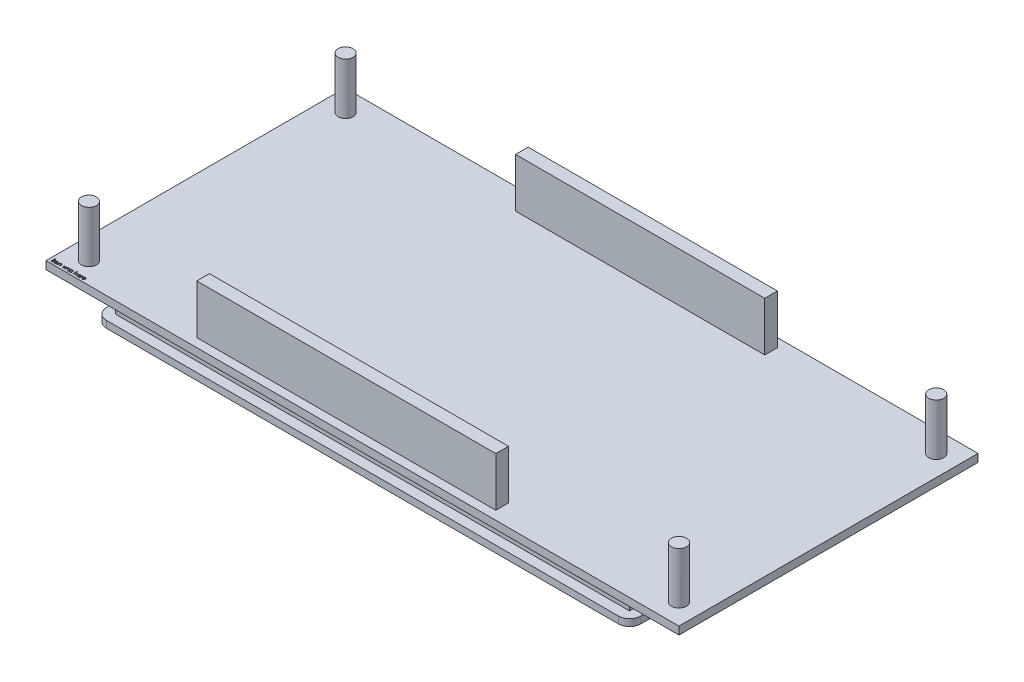
from build123d import *

# Parameters (mm, degrees)
SKETCH1_W           = 127
SKETCH1_H           = 60
BOSS_EXTRUDE1_DEPTH = 1.57
SKETCH2_R           = 1.5
BOSS_EXTRUDE2_DEPTH = 10.33
SKETCH3_W           = 107.2
SKETCH3_H           = 60
SKETCH3_W_2         = 88.657891226
SKETCH3_H_2         = 49.621954044
BOSS_EXTRUDE3_DEPTH = 4.13
SKETCH4_W           = 107.2
SKETCH4_H           = 60
SKETCH4_W_2         = 103.2
SKETCH4_H_2         = 56
CUT_EXTRUDE1_DEPTH  = 2.75
FILLET1_R           = 2.25
SKETCH5_W           = 88.657891226
SKETCH5_H           = 49.621954044
BOSS_EXTRUDE4_DEPTH = 4
SKETCH6_W           = 50
SKETCH6_H           = 2.54
SKETCH6_W_2         = 60
BOSS_EXTRUDE5_DEPTH = 9.85
BOSS_EXTRUDE6_DEPTH = 0.1


with BuildPart() as part:
    # Sketch1 → Boss-Extrude1 (new body)
    with BuildSketch(Plane(origin=(0, 0, 0), x_dir=(1, 0, 0), z_dir=(0, 1, 0))):
        with Locations((63.5, 30)):
            Rectangle(SKETCH1_W, SKETCH1_H)
    extrude(amount=BOSS_EXTRUDE1_DEPTH)

    # Sketch2 → Boss-Extrude2 (add)
    with BuildSketch(Plane(origin=(0, 1.57, 0), x_dir=(1, 0, 0), z_dir=(0, 1, 0))):
        with Locations((4.31, 55.81)):
            Circle(SKETCH2_R)
        with Locations((4.31, 4.31)):
            Circle(SKETCH2_R)
        with Locations((122.81, 4.19)):
            Circle(SKETCH2_R)
        with Locations((122.81, 55.81)):
            Circle(SKETCH2_R)
    extrude(amount=BOSS_EXTRUDE2_DEPTH)

    # Sketch3 → Boss-Extrude3 (add)
    with BuildSketch(Plane.XZ):
        with Locations((63.5, -30)):
            Rectangle(SKETCH3_W, SKETCH3_H)
        with Locations((63.5, -30)):
            Rectangle(SKETCH3_W_2, SKETCH3_H_2, mode=Mode.SUBTRACT)
    extrude(amount=BOSS_EXTRUDE3_DEPTH)

    # Sketch4 → Cut-Extrude1 (cut)
    with BuildSketch(Plane.XZ):
        with Locations((63.5, -30)):
            Rectangle(SKETCH4_W, SKETCH4_H)
        with Locations((63.5, -30)):
            Rectangle(SKETCH4_W_2, SKETCH4_H_2, mode=Mode.SUBTRACT)
    extrude(amount=CUT_EXTRUDE1_DEPTH, mode=Mode.SUBTRACT)

    # Fillet1
    fillet1_edges = [part.edges().sort_by_distance(p)[0] for p in [
        (117.1, -3.44, -60),
        (117.1, -3.44, 0),
        (9.9, -3.44, 0),
        (9.9, -3.44, -60),
    ]]
    fillet(fillet1_edges, radius=FILLET1_R)

    # Sketch5 → Boss-Extrude4 (add)
    with BuildSketch(Plane.XZ):
        with Locations((63.5, -30)):
            Rectangle(SKETCH5_W, SKETCH5_H)
    extrude(amount=BOSS_EXTRUDE4_DEPTH)

    # Sketch6 → Boss-Extrude5 (add)
    with BuildSketch(Plane(origin=(0, 1.57, 0), x_dir=(1, 0, 0), z_dir=(0, 1, 0))):
        with Locations((63.5, 56.98)):
            Rectangle(SKETCH6_W, SKETCH6_H)
        with Locations((58.5, 3.02)):
            Rectangle(SKETCH6_W_2, SKETCH6_H)
    extrude(amount=BOSS_EXTRUDE5_DEPTH)

    # Sketch7 → Boss-Extrude6 (add)
    with BuildSketch(Plane(origin=(0, 1.57, 0), x_dir=(1, 0, 0), z_dir=(0, 1, 0))):
        with BuildLine():
            Line((0.608390087, 1.15544413), (0.754724222, 1.15544413))
            add(Edge.make_bspline(
                [(0.754724222, 1.15544413), (0.761887467, 1.155406469), (0.77577162, 1.155333473), (0.7959615, 1.154201373), (0.814871959, 1.15265773), (0.832508482, 1.150208424), (0.848862918, 1.147253043), (0.863984555, 1.143674083), (0.877825306, 1.139382665), (0.894349464, 1.132558462), (0.913189605, 1.122417783), (0.933589261, 1.107433091), (0.951033027, 1.089104706), (0.966072952, 1.068429851), (0.978030334, 1.045686472), (0.986680898, 1.021416645), (0.992157586, 0.995933415), (0.992720822, 0.978438448), (0.993005472, 0.969596774)],
                knots=[0, 0, 0, 0, 2.1486e-05, 4.1646e-05, 6.0648e-05, 7.839e-05, 9.504e-05, 0.00011049, 0.000124983, 0.000138459, 0.000164071, 0.000188981, 0.000214056, 0.00023966, 0.000265467, 0.000290843, 0.000316773, 0.000343267, 0.000343267, 0.000343267, 0.000343267], degree=3))
            add(Edge.make_bspline(
                [(0.993005472, 0.969596774), (0.992771211, 0.961314083), (0.992310866, 0.945037815), (0.987908846, 0.921231935), (0.981017274, 0.898570959), (0.971437578, 0.877137591), (0.95898715, 0.857416102), (0.944231796, 0.839247403), (0.926429624, 0.823400748), (0.913091787, 0.814541554), (0.90631677, 0.810041485)],
                knots=[0, 0, 0, 0, 2.4827e-05, 4.8786e-05, 7.2358e-05, 9.5759e-05, 0.000118979, 0.000142139, 0.000165758, 0.000190141, 0.000190141, 0.000190141, 0.000190141], degree=3))
            add(Edge.make_bspline(
                [(0.90631677, 0.810041485), (0.914836862, 0.806770414), (0.931137908, 0.800512045), (0.953570624, 0.789447302), (0.972898091, 0.777412564), (0.989268908, 0.764270025), (1.003269834, 0.750103851), (1.015495465, 0.734706327), (1.025927188, 0.717876593), (1.034865671, 0.699790121), (1.041840405, 0.680631592), (1.047063813, 0.660580712), (1.050056838, 0.639709378), (1.050482761, 0.625505369), (1.05069778, 0.618334755)],
                knots=[0, 0, 0, 0, 2.7369e-05, 5.2364e-05, 7.4914e-05, 9.5539e-05, 0.000115193, 0.00013455, 0.000154393, 0.000174484, 0.00019497, 0.000215449, 0.000236547, 0.000258057, 0.000258057, 0.000258057, 0.000258057], degree=3))
            add(Edge.make_bspline(
                [(1.05069778, 0.618334755), (1.050488456, 0.611013282), (1.050076604, 0.596608079), (1.047038039, 0.575446265), (1.04189323, 0.555223062), (1.034806556, 0.535807666), (1.025557489, 0.517237637), (1.014301496, 0.499491938), (1.000880447, 0.482748867), (0.985866975, 0.466822376), (0.96888223, 0.452502136), (0.950557425, 0.43974877), (0.930661785, 0.429260328), (0.909522072, 0.420449752), (0.886901147, 0.413719638), (0.862900588, 0.40901123), (0.837541095, 0.405838722), (0.820139006, 0.405577892), (0.811214607, 0.40544413)],
                knots=[0, 0, 0, 0, 2.196e-05, 4.3207e-05, 6.3978e-05, 8.4464e-05, 0.000105091, 0.000126097, 0.000147379, 0.000169376, 0.000191653, 0.000213907, 0.000236222, 0.000258989, 0.000282518, 0.000306885, 0.000332303, 0.000359061, 0.000359061, 0.000359061, 0.000359061], degree=3))
            Line((0.811214607, 0.40544413), (0.608390087, 0.40544413))
            Line((0.608390087, 0.40544413), (0.608390087, 1.15544413))
        make_face()
        with BuildLine():
            Line((0.67569778, 1.078521053), (0.67569778, 0.838136437))
            Line((0.67569778, 0.838136437), (0.720920135, 0.838136437))
            add(Edge.make_bspline(
                [(0.720920135, 0.838136437), (0.727530592, 0.838222135), (0.74030334, 0.838387721), (0.758800461, 0.838862046), (0.775970107, 0.840190198), (0.791782643, 0.841517968), (0.806213167, 0.843676809), (0.819229709, 0.846246549), (0.831036551, 0.848964315), (0.844652168, 0.853586347), (0.860096371, 0.860417278), (0.876560608, 0.871018386), (0.891075137, 0.883645033), (0.903331677, 0.898214524), (0.913362706, 0.914257279), (0.920329931, 0.931517324), (0.925054349, 0.949564496), (0.925481106, 0.961954121), (0.92569778, 0.96824461)],
                knots=[0, 0, 0, 0, 1.9834e-05, 3.8323e-05, 5.5493e-05, 7.1489e-05, 8.5916e-05, 9.9234e-05, 0.000111296, 0.000122223, 0.000142329, 0.000161791, 0.000180744, 0.000199827, 0.000218715, 0.000237241, 0.000255497, 0.000274325, 0.000274325, 0.000274325, 0.000274325], degree=3))
            add(Edge.make_bspline(
                [(0.92569778, 0.96824461), (0.925585027, 0.972407276), (0.92536385, 0.980572798), (0.923552428, 0.992476231), (0.920473662, 1.003671321), (0.91651917, 1.014311488), (0.910993023, 1.024064027), (0.904486566, 1.03326614), (0.896625347, 1.041604451), (0.887677351, 1.049397915), (0.877389789, 1.056307457), (0.865768798, 1.062359049), (0.852657153, 1.067232073), (0.838275827, 1.07149982), (0.822403451, 1.074497311), (0.80522319, 1.076994466), (0.786594321, 1.078265768), (0.773706085, 1.07843406), (0.767043934, 1.078521053)],
                knots=[0, 0, 0, 0, 1.2484e-05, 2.449e-05, 3.6006e-05, 4.7278e-05, 5.8442e-05, 6.9532e-05, 8.1013e-05, 9.273e-05, 0.000105065, 0.000118101, 0.00013194, 0.000146964, 0.000163052, 0.000180347, 0.000199026, 0.000219013, 0.000219013, 0.000219013, 0.000219013], degree=3))
            Line((0.767043934, 1.078521053), (0.67569778, 1.078521053))
        make_face(mode=Mode.SUBTRACT)
        with BuildLine():
            Line((0.67569778, 0.76121336), (0.67569778, 0.482367206))
            Line((0.67569778, 0.482367206), (0.771551145, 0.482367206))
            add(Edge.make_bspline(
                [(0.771551145, 0.482367206), (0.778412343, 0.482449438), (0.791636399, 0.482607929), (0.81072952, 0.483125333), (0.828425899, 0.484302249), (0.844644785, 0.486154931), (0.859561311, 0.488164599), (0.872996533, 0.490867016), (0.88505936, 0.493963222), (0.899046712, 0.498749116), (0.914797463, 0.506184074), (0.931771218, 0.517394266), (0.946862551, 0.53074926), (0.959677964, 0.546205885), (0.970180747, 0.563012598), (0.977821201, 0.580829458), (0.982533528, 0.599362071), (0.983103993, 0.611997796), (0.983390087, 0.618334755)],
                knots=[0, 0, 0, 0, 2.0585e-05, 3.9675e-05, 5.7294e-05, 7.3769e-05, 8.8642e-05, 0.000102432, 0.000114858, 0.000125976, 0.000146743, 0.000166911, 0.000186812, 0.000206971, 0.000226942, 0.000246058, 0.000264933, 0.000283923, 0.000283923, 0.000283923, 0.000283923], degree=3))
            add(Edge.make_bspline(
                [(0.983390087, 0.618334755), (0.983330922, 0.622297613), (0.983213546, 0.630159409), (0.981443414, 0.641712799), (0.978869014, 0.652904058), (0.975540849, 0.663763574), (0.970693821, 0.674095011), (0.965035275, 0.684102703), (0.958400689, 0.693799877), (0.948062654, 0.706059645), (0.9330258, 0.72018472), (0.911660062, 0.734014184), (0.887365998, 0.745167286), (0.869745821, 0.749902888), (0.860643693, 0.752349178)],
                knots=[0, 0, 0, 0, 1.1878e-05, 2.3564e-05, 3.4971e-05, 4.6327e-05, 5.7555e-05, 6.9127e-05, 8.0796e-05, 9.2741e-05, 0.00011719, 0.000142359, 0.000168781, 0.000197015, 0.000197015, 0.000197015, 0.000197015], degree=3))
            add(Edge.make_bspline(
                [(0.860643693, 0.752349178), (0.856994601, 0.753089553), (0.849082617, 0.754694839), (0.836180993, 0.756389347), (0.821451878, 0.757899002), (0.804861261, 0.759015679), (0.786388153, 0.760169938), (0.765993099, 0.760618829), (0.743759388, 0.761154384), (0.728332451, 0.761193199), (0.720319174, 0.76121336)],
                knots=[0, 0, 0, 0, 1.1167e-05, 2.4213e-05, 3.9013e-05, 5.5583e-05, 7.4093e-05, 9.4534e-05, 0.000116775, 0.000140813, 0.000140813, 0.000140813, 0.000140813], degree=3))
            Line((0.720319174, 0.76121336), (0.67569778, 0.76121336))
        make_face(mode=Mode.SUBTRACT)
        with BuildLine():
            Line((1.635132876, 0.578521053), (1.694928549, 0.547120812))
            add(Edge.make_bspline(
                [(1.694928549, 0.547120812), (1.690163564, 0.53866867), (1.680892791, 0.522224148), (1.664949774, 0.499631606), (1.648237187, 0.479307096), (1.630000622, 0.461793598), (1.610785691, 0.446525444), (1.590485836, 0.433167339), (1.568995375, 0.421784799), (1.546313291, 0.412194972), (1.522249102, 0.404821509), (1.496744491, 0.399613461), (1.469750599, 0.396394189), (1.451247846, 0.396020231), (1.441773501, 0.395828745)],
                knots=[0, 0, 0, 0, 2.9091e-05, 5.66e-05, 8.2838e-05, 0.000107914, 0.000132292, 0.000156378, 0.000180708, 0.000205151, 0.000230148, 0.000256077, 0.000283155, 0.00031157, 0.00031157, 0.00031157, 0.00031157], degree=3))
            add(Edge.make_bspline(
                [(1.441773501, 0.395828745), (1.431243077, 0.396074568), (1.410701271, 0.396554098), (1.380799897, 0.400688198), (1.352647164, 0.407432275), (1.326244656, 0.416853462), (1.301657031, 0.429159317), (1.278835419, 0.444150635), (1.257659806, 0.461750404), (1.238797476, 0.48211107), (1.221816644, 0.503900061), (1.206832539, 0.526604893), (1.194305947, 0.550168441), (1.184116102, 0.574440697), (1.175886488, 0.599268674), (1.170150766, 0.624878274), (1.166844391, 0.651200185), (1.166337724, 0.669006757), (1.166082395, 0.677980187)],
                knots=[0, 0, 0, 0, 3.1579e-05, 6.1602e-05, 9.0353e-05, 0.000118297, 0.000145509, 0.000172636, 0.000200048, 0.000227895, 0.000255725, 0.000282852, 0.000309401, 0.000335658, 0.000361742, 0.000387766, 0.000414265, 0.000441185, 0.000441185, 0.000441185, 0.000441185], degree=3))
            add(Edge.make_bspline(
                [(1.166082395, 0.677980187), (1.166309354, 0.686400508), (1.166759156, 0.703088472), (1.169594325, 0.727788231), (1.174618959, 0.751794328), (1.181513886, 0.77512671), (1.190417724, 0.79774631), (1.201310343, 0.819666895), (1.214208709, 0.84086514), (1.22416714, 0.85423724), (1.229183357, 0.860972976)],
                knots=[0, 0, 0, 0, 2.5262e-05, 5.0067e-05, 7.4464e-05, 9.8755e-05, 0.000122972, 0.000147294, 0.000172108, 0.000197293, 0.000197293, 0.000197293, 0.000197293], degree=3))
            add(Edge.make_bspline(
                [(1.229183357, 0.860972976), (1.23597786, 0.869087734), (1.249351634, 0.885060194), (1.271970853, 0.906046978), (1.296463753, 0.923627787), (1.322523387, 0.938200745), (1.350452631, 0.94927367), (1.379876051, 0.957525294), (1.411128676, 0.962149154), (1.432494081, 0.962802261), (1.443426145, 0.963136437)],
                knots=[0, 0, 0, 0, 3.173e-05, 6.2454e-05, 9.2267e-05, 0.000121992, 0.000151788, 0.000182188, 0.000213486, 0.00024628, 0.00024628, 0.00024628, 0.00024628], degree=3))
            add(Edge.make_bspline(
                [(1.443426145, 0.963136437), (1.454664918, 0.962846284), (1.476712827, 0.962277069), (1.508862568, 0.956999998), (1.539282721, 0.948631593), (1.567961115, 0.936812924), (1.594900657, 0.921564448), (1.619926239, 0.902676911), (1.643465848, 0.880730178), (1.657160544, 0.863852347), (1.66412927, 0.855263841)],
                knots=[0, 0, 0, 0, 3.3694e-05, 6.6101e-05, 9.7449e-05, 0.000128168, 0.000158916, 0.000190046, 0.000222037, 0.000255183, 0.000255183, 0.000255183, 0.000255183], degree=3))
            add(Edge.make_bspline(
                [(1.66412927, 0.855263841), (1.668870757, 0.848791645), (1.67832217, 0.835890334), (1.690160834, 0.814853657), (1.700437419, 0.792844244), (1.708651625, 0.769506324), (1.715302946, 0.745116413), (1.720115122, 0.719500154), (1.722937183, 0.692665173), (1.723491904, 0.674380911), (1.723774703, 0.665059514)],
                knots=[0, 0, 0, 0, 2.405e-05, 4.794e-05, 7.2274e-05, 9.6842e-05, 0.000122063, 0.000148053, 0.000174947, 0.000202918, 0.000202918, 0.000202918, 0.000202918], degree=3))
            Line((1.723774703, 0.665059514), (1.233390087, 0.665059514))
            add(Edge.make_bspline(
                [(1.233390087, 0.665059514), (1.233720003, 0.657837986), (1.234368769, 0.643637142), (1.237393442, 0.622857689), (1.242161037, 0.603063401), (1.24886155, 0.584402749), (1.256975874, 0.566632008), (1.266915671, 0.549883), (1.278774146, 0.534232015), (1.292001082, 0.519539057), (1.306724031, 0.506454608), (1.322213191, 0.494743513), (1.338690384, 0.484928028), (1.356025687, 0.476960909), (1.37419107, 0.470723841), (1.393192254, 0.466466451), (1.412991851, 0.463614928), (1.426488794, 0.463297857), (1.433360039, 0.463136437)],
                knots=[0, 0, 0, 0, 2.1677e-05, 4.2627e-05, 6.2887e-05, 8.2655e-05, 0.000102015, 0.000121417, 0.000140948, 0.000160837, 0.000180625, 0.000199946, 0.000219013, 0.000238038, 0.00025709, 0.000276515, 0.000296381, 0.000316984, 0.000316984, 0.000316984, 0.000316984], degree=3))
            add(Edge.make_bspline(
                [(1.433360039, 0.463136437), (1.440078142, 0.463266735), (1.453408148, 0.463525271), (1.47325976, 0.466039252), (1.492789659, 0.470104311), (1.511917012, 0.475652166), (1.530253622, 0.482418634), (1.547234811, 0.490583532), (1.562852, 0.499615621), (1.577448493, 0.509946266), (1.591606563, 0.522590877), (1.605651382, 0.53836996), (1.620710665, 0.557031573), (1.630137006, 0.571077073), (1.635132876, 0.578521053)],
                knots=[0, 0, 0, 0, 2.0146e-05, 3.9974e-05, 5.9922e-05, 7.994e-05, 9.967e-05, 0.000118486, 0.000136395, 0.000153738, 0.000172041, 0.000193204, 0.000217043, 0.000243924, 0.000243924, 0.000243924, 0.000243924], degree=3))
        make_face()
        with BuildLine():
            add(Edge.make_bspline(
                [(1.65646701, 0.732367206), (1.654003448, 0.741294965), (1.649261883, 0.758478027), (1.639354091, 0.782272503), (1.628195904, 0.803419911), (1.614991247, 0.821758403), (1.600030092, 0.83804487), (1.582748981, 0.852277424), (1.563369861, 0.865009735), (1.541992902, 0.8757567), (1.519355377, 0.884904526), (1.49565405, 0.89103848), (1.471470238, 0.895240525), (1.455112891, 0.895631833), (1.446881674, 0.895828745)],
                knots=[0, 0, 0, 0, 2.7759e-05, 5.3427e-05, 7.7157e-05, 9.9337e-05, 0.000121026, 0.000143321, 0.000166323, 0.000190445, 0.000214996, 0.000239414, 0.000263767, 0.000288436, 0.000288436, 0.000288436, 0.000288436], degree=3))
            add(Edge.make_bspline(
                [(1.446881674, 0.895828745), (1.440163937, 0.895697672), (1.426884384, 0.89543857), (1.407319869, 0.892980685), (1.388531362, 0.888917861), (1.370380229, 0.883353942), (1.353104329, 0.875937813), (1.336348307, 0.867241407), (1.320538222, 0.856625353), (1.310650802, 0.84853417), (1.305655712, 0.844446533)],
                knots=[0, 0, 0, 0, 2.0146e-05, 3.9825e-05, 5.9038e-05, 7.7761e-05, 9.668e-05, 0.000115363, 0.000134322, 0.00015368, 0.00015368, 0.00015368, 0.00015368], degree=3))
            add(Edge.make_bspline(
                [(1.305655712, 0.844446533), (1.302078581, 0.841212037), (1.294839337, 0.834666205), (1.285166369, 0.823388518), (1.275904839, 0.811227469), (1.267476199, 0.797717799), (1.259745287, 0.783013347), (1.252511007, 0.767238139), (1.245999633, 0.750272468), (1.24233618, 0.738449803), (1.240451385, 0.732367206)],
                knots=[0, 0, 0, 0, 1.4454e-05, 2.9252e-05, 4.4486e-05, 6.0285e-05, 7.6952e-05, 9.4298e-05, 0.000112322, 0.000131422, 0.000131422, 0.000131422, 0.000131422], degree=3))
            Line((1.240451385, 0.732367206), (1.65646701, 0.732367206))
        make_face(mode=Mode.SUBTRACT)
        with BuildLine():
            Line((1.858390087, 0.953521053), (1.92569778, 0.953521053))
            Line((1.92569778, 0.953521053), (1.92569778, 0.85466288))
            add(Edge.make_bspline(
                [(1.92569778, 0.85466288), (1.932884416, 0.863629177), (1.946830334, 0.881028591), (1.970055548, 0.903897285), (1.99460067, 0.922742691), (2.020315385, 0.937764932), (2.047234601, 0.949089209), (2.07519423, 0.957267623), (2.104361667, 0.962171515), (2.124196904, 0.962812279), (2.134231434, 0.963136437)],
                knots=[0, 0, 0, 0, 3.4452e-05, 6.6856e-05, 9.7506e-05, 0.000127062, 0.000155944, 0.000184898, 0.00021429, 0.000244384, 0.000244384, 0.000244384, 0.000244384], degree=3))
            add(Edge.make_bspline(
                [(2.134231434, 0.963136437), (2.144373712, 0.962762467), (2.164224598, 0.962030516), (2.19312704, 0.956241225), (2.220121339, 0.946352956), (2.245111243, 0.932807513), (2.267638503, 0.915963269), (2.2874224, 0.896339458), (2.303785953, 0.87376744), (2.314756817, 0.852826764), (2.321983741, 0.834250594), (2.326533528, 0.818340576), (2.330397309, 0.800615258), (2.33374697, 0.781128203), (2.336013494, 0.759742877), (2.337801128, 0.736546943), (2.339082276, 0.711547915), (2.339133107, 0.694257923), (2.339159318, 0.685341966)],
                knots=[0, 0, 0, 0, 3.0411e-05, 5.9522e-05, 8.7992e-05, 0.000116362, 0.000144487, 0.000172108, 0.000199635, 0.000227792, 0.000242775, 0.000259368, 0.000277374, 0.000297183, 0.000318653, 0.00034186, 0.000366979, 0.000393723, 0.000393723, 0.000393723, 0.000393723], degree=3))
            Line((2.339159318, 0.685341966), (2.339159318, 0.40544413))
            Line((2.339159318, 0.40544413), (2.271851626, 0.40544413))
            Line((2.271851626, 0.40544413), (2.271851626, 0.66325663))
            add(Edge.make_bspline(
                [(2.271851626, 0.66325663), (2.271810224, 0.670718582), (2.27173103, 0.684992027), (2.271481248, 0.705428246), (2.270879147, 0.723961085), (2.27003308, 0.740546235), (2.268794716, 0.755167771), (2.267504152, 0.767855473), (2.265925943, 0.778593232), (2.264519604, 0.785057179), (2.263888885, 0.787956149)],
                knots=[0, 0, 0, 0, 2.2386e-05, 4.2821e-05, 6.1311e-05, 7.8012e-05, 9.2634e-05, 0.000105327, 0.00011627, 0.000125168, 0.000125168, 0.000125168, 0.000125168], degree=3))
            add(Edge.make_bspline(
                [(2.263888885, 0.787956149), (2.261611986, 0.796465688), (2.257229659, 0.812843919), (2.246400948, 0.835059852), (2.232726481, 0.853959464), (2.216034084, 0.869425904), (2.196484997, 0.881462512), (2.174133466, 0.889814074), (2.149195186, 0.89503756), (2.131654961, 0.89555766), (2.122512684, 0.895828745)],
                knots=[0, 0, 0, 0, 2.6378e-05, 5.0769e-05, 7.3667e-05, 9.5993e-05, 0.000118592, 0.000142085, 0.000167248, 0.000194642, 0.000194642, 0.000194642, 0.000194642], degree=3))
            add(Edge.make_bspline(
                [(2.122512684, 0.895828745), (2.11709818, 0.895726744), (2.106383017, 0.895524887), (2.090493737, 0.893499608), (2.075081415, 0.890187082), (2.05999137, 0.885715231), (2.045525414, 0.879573317), (2.03121878, 0.872602737), (2.017610188, 0.863913835), (2.00440946, 0.85423013), (1.992128144, 0.843498871), (1.980700643, 0.832175048), (1.970513924, 0.82011599), (1.961284922, 0.807516001), (1.953318152, 0.794202036), (1.946363919, 0.780302541), (1.940463413, 0.765799224), (1.937531407, 0.755733139), (1.936064366, 0.750696533)],
                knots=[0, 0, 0, 0, 1.6237e-05, 3.2133e-05, 4.7957e-05, 6.3498e-05, 7.9262e-05, 9.5052e-05, 0.000111184, 0.000127621, 0.000144129, 0.000160064, 0.000175839, 0.000191436, 0.000206869, 0.000222323, 0.00023803, 0.00025376, 0.00025376, 0.00025376, 0.00025376], degree=3))
            add(Edge.make_bspline(
                [(1.936064366, 0.750696533), (1.935220156, 0.74699899), (1.933382354, 0.738949631), (1.931397387, 0.725740113), (1.929595763, 0.710459404), (1.928087844, 0.693125336), (1.927165255, 0.67367722), (1.926159312, 0.652198112), (1.925793085, 0.628602364), (1.925730438, 0.612174858), (1.92569778, 0.603611197)],
                knots=[0, 0, 0, 0, 1.1375e-05, 2.4762e-05, 4.0043e-05, 5.7536e-05, 7.6945e-05, 9.8448e-05, 0.00012204, 0.000147732, 0.000147732, 0.000147732, 0.000147732], degree=3))
            Line((1.92569778, 0.603611197), (1.92569778, 0.40544413))
            Line((1.92569778, 0.40544413), (1.858390087, 0.40544413))
            Line((1.858390087, 0.40544413), (1.858390087, 0.953521053))
        make_face()
        Polygon((2.704543934, 0.953521053), (2.776809559, 0.953521053), (2.940120857, 0.559290283), (3.119057155, 0.953521053), (3.130475424, 0.953521053), (3.305505472, 0.559290283), (3.470319174, 0.953521053), (3.541082395, 0.953521053), (3.311965809, 0.40544413), (3.297993453, 0.40544413), (3.122813164, 0.799674899), (2.944027107, 0.40544413), (2.931557155, 0.40544413), align=None)
        with BuildLine():
            Line((4.185313164, 0.953521053), (4.185313164, 0.40544413))
            Line((4.185313164, 0.40544413), (4.118005472, 0.40544413))
            Line((4.118005472, 0.40544413), (4.118005472, 0.500245812))
            add(Edge.make_bspline(
                [(4.118005472, 0.500245812), (4.110415731, 0.491665899), (4.095604256, 0.474922091), (4.070866874, 0.45304734), (4.044645122, 0.434966271), (4.017066267, 0.420362718), (3.988155215, 0.409392991), (3.957976053, 0.401595957), (3.926516472, 0.396582993), (3.905033824, 0.396082416), (3.894147299, 0.395828745)],
                knots=[0, 0, 0, 0, 3.4342e-05, 6.7019e-05, 9.8775e-05, 0.000129689, 0.00016041, 0.000191311, 0.000223077, 0.000255714, 0.000255714, 0.000255714, 0.000255714], degree=3))
            add(Edge.make_bspline(
                [(3.894147299, 0.395828745), (3.884468452, 0.396091539), (3.865381336, 0.396609781), (3.837303677, 0.400630274), (3.810283909, 0.407086836), (3.784296501, 0.416065598), (3.759509612, 0.427975774), (3.73571102, 0.442234613), (3.713024015, 0.459214791), (3.691794399, 0.478626511), (3.672244685, 0.499711151), (3.655088698, 0.522199483), (3.640784467, 0.545994262), (3.628823021, 0.570794224), (3.619609518, 0.596790278), (3.613186597, 0.623892528), (3.609170787, 0.65206893), (3.608652759, 0.67125597), (3.608390087, 0.680984995)],
                knots=[0, 0, 0, 0, 2.9028e-05, 5.7244e-05, 8.4902e-05, 0.000112271, 0.000139555, 0.000167254, 0.000195379, 0.000224414, 0.00025344, 0.000281535, 0.000309105, 0.00033659, 0.000364008, 0.000391666, 0.000420031, 0.000449209, 0.000449209, 0.000449209, 0.000449209], degree=3))
            add(Edge.make_bspline(
                [(3.608390087, 0.680984995), (3.608658581, 0.690512931), (3.609189379, 0.709349148), (3.613143641, 0.737051726), (3.619793142, 0.76373421), (3.629124824, 0.789310698), (3.641090957, 0.813812138), (3.655646976, 0.837255857), (3.672793931, 0.859706442), (3.692562304, 0.880635991), (3.713976898, 0.89996898), (3.736885911, 0.916770918), (3.760719472, 0.931281671), (3.78584726, 0.942778845), (3.811897354, 0.952080796), (3.839101663, 0.958516432), (3.867347002, 0.962308715), (3.886523536, 0.962857879), (3.896250664, 0.963136437)],
                knots=[0, 0, 0, 0, 2.8578e-05, 5.6497e-05, 8.3753e-05, 0.000110939, 0.000138018, 0.00016541, 0.000193596, 0.000222614, 0.000251661, 0.000280027, 0.000307725, 0.000335218, 0.000362778, 0.000390582, 0.000418927, 0.000448105, 0.000448105, 0.000448105, 0.000448105], degree=3))
            add(Edge.make_bspline(
                [(3.896250664, 0.963136437), (3.907436348, 0.962828348), (3.929370947, 0.962224198), (3.96145552, 0.957196471), (3.991807908, 0.948702514), (4.020662412, 0.937148764), (4.047915417, 0.921795465), (4.073308913, 0.902428331), (4.09710866, 0.879169505), (4.110904436, 0.86130441), (4.118005472, 0.852108793)],
                knots=[0, 0, 0, 0, 3.3544e-05, 6.5779e-05, 9.7127e-05, 0.000127928, 0.000158807, 0.000190658, 0.000223487, 0.000258307, 0.000258307, 0.000258307, 0.000258307], degree=3))
            Line((4.118005472, 0.852108793), (4.118005472, 0.953521053))
            Line((4.118005472, 0.953521053), (4.185313164, 0.953521053))
        make_face()
        with BuildLine():
            add(Edge.make_bspline(
                [(3.897152107, 0.895828745), (3.88731332, 0.89547868), (3.86789312, 0.894787707), (3.839383691, 0.889393386), (3.812102245, 0.880418116), (3.786185229, 0.868143423), (3.76204204, 0.852708694), (3.740464825, 0.834039826), (3.721277103, 0.81264618), (3.705139618, 0.788624299), (3.691984511, 0.762871851), (3.682734433, 0.735952329), (3.67663388, 0.708351262), (3.676010626, 0.689630686), (3.67569778, 0.680233793)],
                knots=[0, 0, 0, 0, 2.9502e-05, 5.8233e-05, 8.6692e-05, 0.000115455, 0.000144044, 0.000172382, 0.000200792, 0.000230003, 0.000258962, 0.000287281, 0.000315214, 0.000343367, 0.000343367, 0.000343367, 0.000343367], degree=3))
            add(Edge.make_bspline(
                [(3.67569778, 0.680233793), (3.6760974, 0.670893056), (3.676895073, 0.652248194), (3.682627365, 0.624609499), (3.692244481, 0.597683633), (3.70536778, 0.571699134), (3.721800628, 0.54757397), (3.740848196, 0.525772515), (3.762694685, 0.507024746), (3.786893437, 0.49133098), (3.812738002, 0.478653297), (3.839916701, 0.469832089), (3.867918624, 0.46413685), (3.88695841, 0.463471605), (3.896551145, 0.463136437)],
                knots=[0, 0, 0, 0, 2.8013e-05, 5.5916e-05, 8.4284e-05, 0.000113579, 0.000142999, 0.000171633, 0.000200184, 0.000229062, 0.000257955, 0.000286272, 0.000314587, 0.00034334, 0.00034334, 0.00034334, 0.00034334], degree=3))
            add(Edge.make_bspline(
                [(3.896551145, 0.463136437), (3.906289681, 0.463492144), (3.925658664, 0.464199609), (3.954252673, 0.469617023), (3.982001594, 0.47856748), (4.008527428, 0.490974435), (4.033238028, 0.506351012), (4.055416144, 0.524352531), (4.074169566, 0.545288928), (4.090067983, 0.568298168), (4.102534143, 0.593522167), (4.111614727, 0.620379493), (4.116983421, 0.648871082), (4.117660078, 0.668341924), (4.118005472, 0.678280668)],
                knots=[0, 0, 0, 0, 2.9202e-05, 5.8081e-05, 8.6968e-05, 0.000116475, 0.000145699, 0.000174092, 0.000201854, 0.000229733, 0.000257751, 0.000285973, 0.000314555, 0.000344358, 0.000344358, 0.000344358, 0.000344358], degree=3))
            add(Edge.make_bspline(
                [(4.118005472, 0.678280668), (4.117799831, 0.68585306), (4.117395065, 0.700757925), (4.114302801, 0.722642393), (4.109383888, 0.743585334), (4.102452566, 0.763608767), (4.09334729, 0.782601985), (4.082365626, 0.800701362), (4.069314458, 0.817812764), (4.054403881, 0.833700565), (4.038082766, 0.84819195), (4.020812507, 0.861127145), (4.00238849, 0.87175331), (3.983120553, 0.880547868), (3.962975268, 0.887546258), (3.941788706, 0.892215049), (3.919786066, 0.895420832), (3.904776197, 0.895691342), (3.897152107, 0.895828745)],
                knots=[0, 0, 0, 0, 2.2711e-05, 4.4702e-05, 6.6166e-05, 8.7167e-05, 0.000108134, 0.000129237, 0.000150572, 0.000172575, 0.000194497, 0.000215982, 0.000237189, 0.000258165, 0.00027945, 0.000301027, 0.000323167, 0.000346021, 0.000346021, 0.000346021, 0.000346021], degree=3))
        make_face(mode=Mode.SUBTRACT)
        with BuildLine():
            Line((4.598774703, 0.885161678), (4.553101626, 0.838136437))
            add(Edge.make_bspline(
                [(4.553101626, 0.838136437), (4.549160804, 0.84270354), (4.541563362, 0.851508377), (4.529513759, 0.863280605), (4.517508701, 0.873167092), (4.505712527, 0.881514005), (4.493828612, 0.887824536), (4.481996416, 0.892430578), (4.470203686, 0.895280965), (4.462320964, 0.895648345), (4.458450184, 0.895828745)],
                knots=[0, 0, 0, 0, 1.8091e-05, 3.4878e-05, 5.046e-05, 6.4713e-05, 7.8155e-05, 9.071e-05, 0.000102737, 0.000114341, 0.000114341, 0.000114341, 0.000114341], degree=3))
            add(Edge.make_bspline(
                [(4.458450184, 0.895828745), (4.453706029, 0.895598415), (4.444370203, 0.895145158), (4.430993242, 0.890620852), (4.418575251, 0.883676122), (4.407827327, 0.873825711), (4.398722824, 0.862519082), (4.392077035, 0.849877013), (4.388012896, 0.836281003), (4.387497596, 0.826846034), (4.387236241, 0.822060716)],
                knots=[0, 0, 0, 0, 1.4187e-05, 2.7918e-05, 4.1913e-05, 5.6598e-05, 7.1357e-05, 8.5268e-05, 9.9198e-05, 0.000113535, 0.000113535, 0.000113535, 0.000113535], degree=3))
            add(Edge.make_bspline(
                [(4.387236241, 0.822060716), (4.387474272, 0.817729564), (4.387949664, 0.809079469), (4.391645381, 0.796319176), (4.397530968, 0.783878382), (4.403031724, 0.776257759), (4.405866049, 0.772331149)],
                knots=[0, 0, 0, 0, 1.2976e-05, 2.5916e-05, 3.9558e-05, 5.406e-05, 5.406e-05, 5.406e-05, 5.406e-05], degree=3))
            add(Edge.make_bspline(
                [(4.405866049, 0.772331149), (4.407572512, 0.770234452), (4.411204503, 0.765771898), (4.418020614, 0.759578215), (4.425739721, 0.752733447), (4.435022565, 0.745889839), (4.445469214, 0.73868304), (4.457306203, 0.731396869), (4.470157883, 0.723475921), (4.479358734, 0.718452113), (4.484141289, 0.715840764)],
                knots=[0, 0, 0, 0, 8.099e-06, 1.7238e-05, 2.757e-05, 3.9048e-05, 5.18e-05, 6.5639e-05, 8.0738e-05, 9.7082e-05, 9.7082e-05, 9.7082e-05, 9.7082e-05], degree=3))
            add(Edge.make_bspline(
                [(4.484141289, 0.715840764), (4.48997277, 0.712573999), (4.501237271, 0.706263685), (4.517242864, 0.696468749), (4.531768658, 0.686733444), (4.54493773, 0.677161885), (4.556496689, 0.66748627), (4.566796236, 0.658077465), (4.575579474, 0.648651185), (4.580498173, 0.642065518), (4.582849222, 0.638917687)],
                knots=[0, 0, 0, 0, 2.0051e-05, 3.8733e-05, 5.6275e-05, 7.2502e-05, 8.7545e-05, 0.000101472, 0.000114337, 0.000126118, 0.000126118, 0.000126118, 0.000126118], degree=3))
            add(Edge.make_bspline(
                [(4.582849222, 0.638917687), (4.586751478, 0.632560668), (4.594517691, 0.619909021), (4.602673034, 0.599076501), (4.607400236, 0.576981393), (4.608056426, 0.561867346), (4.608390087, 0.55418211)],
                knots=[0, 0, 0, 0, 2.2343e-05, 4.4468e-05, 6.6745e-05, 8.9791e-05, 8.9791e-05, 8.9791e-05, 8.9791e-05], degree=3))
            add(Edge.make_bspline(
                [(4.608390087, 0.55418211), (4.608235902, 0.548767293), (4.607932062, 0.538096805), (4.605819619, 0.522382198), (4.602186409, 0.507353365), (4.597237748, 0.492847232), (4.590555382, 0.479141745), (4.582723711, 0.46589112), (4.573321945, 0.453381992), (4.562588078, 0.441630787), (4.550835473, 0.430898126), (4.538298443, 0.421464422), (4.524961551, 0.413627064), (4.510920093, 0.407141633), (4.496142167, 0.401984149), (4.480625462, 0.398413607), (4.464419301, 0.396276586), (4.453398628, 0.395979913), (4.447783116, 0.395828745)],
                knots=[0, 0, 0, 0, 1.6243e-05, 3.2009e-05, 4.746e-05, 6.2569e-05, 7.7891e-05, 9.3119e-05, 0.000108684, 0.000124742, 0.000140801, 0.000156366, 0.000171723, 0.000187117, 0.000202701, 0.000218591, 0.000234803, 0.000251647, 0.000251647, 0.000251647, 0.000251647], degree=3))
            add(Edge.make_bspline(
                [(4.447783116, 0.395828745), (4.440204436, 0.396041466), (4.42515238, 0.396463954), (4.402890297, 0.400429538), (4.381135849, 0.40659998), (4.360053662, 0.415110537), (4.340115209, 0.425857118), (4.321872868, 0.438727631), (4.305263269, 0.453296916), (4.295809353, 0.464463969), (4.291082395, 0.470047495)],
                knots=[0, 0, 0, 0, 2.2718e-05, 4.5121e-05, 6.7615e-05, 9.0464e-05, 0.000113186, 0.000135403, 0.000157324, 0.000179246, 0.000179246, 0.000179246, 0.000179246], degree=3))
            Line((4.291082395, 0.470047495), (4.335703789, 0.520828745))
            add(Edge.make_bspline(
                [(4.335703789, 0.520828745), (4.339940735, 0.516252724), (4.348154695, 0.507381415), (4.36129067, 0.495569057), (4.374657684, 0.485668784), (4.38812226, 0.477388053), (4.401883709, 0.471007609), (4.415864912, 0.466525053), (4.430037431, 0.463644155), (4.43955646, 0.463305951), (4.444327587, 0.463136437)],
                knots=[0, 0, 0, 0, 1.8702e-05, 3.6257e-05, 5.2904e-05, 6.8544e-05, 8.3602e-05, 9.8284e-05, 0.000112515, 0.000126816, 0.000126816, 0.000126816, 0.000126816], degree=3))
            add(Edge.make_bspline(
                [(4.444327587, 0.463136437), (4.450824286, 0.463430185), (4.463517745, 0.46400412), (4.48169855, 0.469214926), (4.498485399, 0.477385629), (4.51306183, 0.488975208), (4.525469436, 0.502465688), (4.534454045, 0.51766157), (4.540084654, 0.534116882), (4.540745939, 0.545523804), (4.541082395, 0.551327543)],
                knots=[0, 0, 0, 0, 1.9451e-05, 3.8005e-05, 5.628e-05, 7.5123e-05, 9.3527e-05, 0.000110971, 0.000127742, 0.000145114, 0.000145114, 0.000145114, 0.000145114], degree=3))
            add(Edge.make_bspline(
                [(4.541082395, 0.551327543), (4.540849618, 0.556108176), (4.54039003, 0.565546895), (4.536780757, 0.579207682), (4.531078003, 0.592165385), (4.525462722, 0.599748881), (4.522602828, 0.603611197)],
                knots=[0, 0, 0, 0, 1.4323e-05, 2.828e-05, 4.2131e-05, 5.6508e-05, 5.6508e-05, 5.6508e-05, 5.6508e-05], degree=3))
            add(Edge.make_bspline(
                [(4.522602828, 0.603611197), (4.520883743, 0.605547346), (4.517138956, 0.609764978), (4.510269976, 0.615856066), (4.502045291, 0.622421373), (4.492372399, 0.629349571), (4.4812318, 0.636549272), (4.468578341, 0.643982704), (4.454585366, 0.652002931), (4.444691659, 0.657321429), (4.439519895, 0.660101581)],
                knots=[0, 0, 0, 0, 7.762e-06, 1.6908e-05, 2.749e-05, 3.9331e-05, 5.2583e-05, 6.727e-05, 8.3352e-05, 0.000100966, 0.000100966, 0.000100966, 0.000100966], degree=3))
            add(Edge.make_bspline(
                [(4.439519895, 0.660101581), (4.433938472, 0.66321711), (4.423114312, 0.669259113), (4.40778275, 0.678669702), (4.393951174, 0.688241261), (4.381286765, 0.697436869), (4.370109407, 0.706741357), (4.360463132, 0.716165054), (4.351968157, 0.725327908), (4.34726514, 0.731820186), (4.345018693, 0.734921293)],
                knots=[0, 0, 0, 0, 1.9176e-05, 3.7187e-05, 5.394e-05, 6.9625e-05, 8.413e-05, 9.7517e-05, 0.000110069, 0.000121547, 0.000121547, 0.000121547, 0.000121547], degree=3))
            add(Edge.make_bspline(
                [(4.345018693, 0.734921293), (4.341133565, 0.741166782), (4.33336195, 0.753659942), (4.325815838, 0.774512187), (4.320628831, 0.7964647), (4.320165462, 0.811611883), (4.319928549, 0.819356389)],
                knots=[0, 0, 0, 0, 2.2008e-05, 4.4024e-05, 6.6186e-05, 8.9372e-05, 8.9372e-05, 8.9372e-05, 8.9372e-05], degree=3))
            add(Edge.make_bspline(
                [(4.319928549, 0.819356389), (4.320043019, 0.824418974), (4.320267054, 0.834327171), (4.322055065, 0.84888549), (4.325310432, 0.862717237), (4.32939363, 0.876030136), (4.335068559, 0.888566299), (4.341849825, 0.9004929), (4.349818558, 0.911793454), (4.358999264, 0.922294125), (4.369093545, 0.931831838), (4.379999567, 0.94014583), (4.39147205, 0.947240049), (4.403559569, 0.953189726), (4.416378242, 0.957690022), (4.429838467, 0.960788033), (4.443913, 0.962857005), (4.45353467, 0.963041952), (4.458450184, 0.963136437)],
                knots=[0, 0, 0, 0, 1.5186e-05, 2.9721e-05, 4.3899e-05, 5.7773e-05, 7.1426e-05, 8.5086e-05, 9.8883e-05, 0.000112833, 0.000126863, 0.000140475, 0.0001539, 0.000167272, 0.000180814, 0.000194553, 0.000208661, 0.000223397, 0.000223397, 0.000223397, 0.000223397], degree=3))
            add(Edge.make_bspline(
                [(4.458450184, 0.963136437), (4.464277054, 0.962899793), (4.476040102, 0.962422065), (4.493687522, 0.958627988), (4.511308952, 0.95238518), (4.52894967, 0.94376313), (4.546480446, 0.932605942), (4.564055487, 0.919121093), (4.581885779, 0.903397297), (4.593019275, 0.891376034), (4.598774703, 0.885161678)],
                knots=[0, 0, 0, 0, 1.7469e-05, 3.5266e-05, 5.3892e-05, 7.3446e-05, 9.4037e-05, 0.000116123, 0.000139854, 0.00016525, 0.00016525, 0.00016525, 0.00016525], degree=3))
        make_face()
        with BuildLine():
            Line((5.03146701, 1.174674899), (5.098774703, 1.174674899))
            Line((5.098774703, 1.174674899), (5.098774703, 0.850005428))
            add(Edge.make_bspline(
                [(5.098774703, 0.850005428), (5.105999839, 0.859036281), (5.120067549, 0.876619815), (5.143745288, 0.899561499), (5.168060475, 0.919446918), (5.193852934, 0.935276301), (5.220649474, 0.947781275), (5.248563113, 0.956650056), (5.277599035, 0.962103863), (5.29731871, 0.962789238), (5.307308357, 0.963136437)],
                knots=[0, 0, 0, 0, 3.4664e-05, 6.7492e-05, 9.8699e-05, 0.000128719, 0.000158027, 0.0001872, 0.000216374, 0.000246326, 0.000246326, 0.000246326, 0.000246326], degree=3))
            add(Edge.make_bspline(
                [(5.307308357, 0.963136437), (5.317450584, 0.962762416), (5.337301368, 0.962030368), (5.366204539, 0.956241786), (5.393196155, 0.946350906), (5.418195978, 0.932815115), (5.440658414, 0.915956652), (5.460554792, 0.896492755), (5.476806391, 0.873934058), (5.487863345, 0.853093432), (5.495057647, 0.834549413), (5.499611609, 0.818641589), (5.503472866, 0.800915465), (5.506837095, 0.781380165), (5.509079291, 0.759941914), (5.510880281, 0.736697431), (5.51216095, 0.711648049), (5.512210579, 0.694307995), (5.512236241, 0.685341966)],
                knots=[0, 0, 0, 0, 3.0411e-05, 5.9522e-05, 8.7992e-05, 0.000116362, 0.000144487, 0.000172002, 0.000199529, 0.000227553, 0.000242536, 0.000259129, 0.000277135, 0.000296944, 0.000318563, 0.00034177, 0.000366889, 0.000393784, 0.000393784, 0.000393784, 0.000393784], degree=3))
            Line((5.512236241, 0.685341966), (5.512236241, 0.40544413))
            Line((5.512236241, 0.40544413), (5.444928549, 0.40544413))
            Line((5.444928549, 0.40544413), (5.444928549, 0.66325663))
            add(Edge.make_bspline(
                [(5.444928549, 0.66325663), (5.44488777, 0.67071863), (5.444809766, 0.684992167), (5.444551906, 0.705427762), (5.443976289, 0.723962648), (5.443046112, 0.740537423), (5.442067832, 0.755175196), (5.440721407, 0.767854707), (5.439154928, 0.778593373), (5.437747332, 0.785057222), (5.437116049, 0.787956149)],
                knots=[0, 0, 0, 0, 2.2386e-05, 4.2821e-05, 6.1311e-05, 7.8012e-05, 9.2623e-05, 0.000105315, 0.000116258, 0.000125157, 0.000125157, 0.000125157, 0.000125157], degree=3))
            add(Edge.make_bspline(
                [(5.437116049, 0.787956149), (5.434667996, 0.796462062), (5.42996163, 0.812814632), (5.419022777, 0.835028005), (5.405360132, 0.853967593), (5.388678576, 0.869377797), (5.369273212, 0.881465984), (5.347017506, 0.889837652), (5.32212092, 0.895033592), (5.304581319, 0.8955563), (5.295439366, 0.895828745)],
                knots=[0, 0, 0, 0, 2.6512e-05, 5.097e-05, 7.3868e-05, 9.6194e-05, 0.000118664, 0.000142017, 0.000167181, 0.000194574, 0.000194574, 0.000194574, 0.000194574], degree=3))
            add(Edge.make_bspline(
                [(5.295439366, 0.895828745), (5.290024843, 0.895726782), (5.279309643, 0.895525), (5.263420643, 0.893499165), (5.248007272, 0.890188725), (5.232921091, 0.885709181), (5.218481834, 0.879613709), (5.204268622, 0.87255724), (5.190684149, 0.863919757), (5.177487188, 0.854228521), (5.165204859, 0.843499287), (5.15377762, 0.832174939), (5.143590833, 0.820116018), (5.134361849, 0.807515993), (5.126395074, 0.794202038), (5.119440842, 0.780302541), (5.113540336, 0.765799224), (5.11060833, 0.755733139), (5.109141289, 0.750696533)],
                knots=[0, 0, 0, 0, 1.6237e-05, 3.2133e-05, 4.7957e-05, 6.3498e-05, 7.9262e-05, 9.4917e-05, 0.00011105, 0.000127487, 0.000143995, 0.00015993, 0.000175705, 0.000191301, 0.000206735, 0.000222189, 0.000237896, 0.000253625, 0.000253625, 0.000253625, 0.000253625], degree=3))
            add(Edge.make_bspline(
                [(5.109141289, 0.750696533), (5.108297126, 0.747049187), (5.106457591, 0.73910117), (5.104461556, 0.725992386), (5.102674885, 0.710759592), (5.101164481, 0.693425892), (5.100238106, 0.673927768), (5.099239911, 0.652398277), (5.098868337, 0.628702558), (5.098806847, 0.61222495), (5.098774703, 0.603611197)],
                knots=[0, 0, 0, 0, 1.1228e-05, 2.4467e-05, 3.9748e-05, 5.724e-05, 7.665e-05, 9.8303e-05, 0.000121895, 0.000147737, 0.000147737, 0.000147737, 0.000147737], degree=3))
            Line((5.098774703, 0.603611197), (5.098774703, 0.40544413))
            Line((5.098774703, 0.40544413), (5.03146701, 0.40544413))
            Line((5.03146701, 0.40544413), (5.03146701, 1.174674899))
        make_face()
        with BuildLine():
            Line((6.115902107, 0.578521053), (6.17569778, 0.547120812))
            add(Edge.make_bspline(
                [(6.17569778, 0.547120812), (6.170932795, 0.53866867), (6.161662022, 0.522224148), (6.145719004, 0.499631606), (6.129006417, 0.479307096), (6.110769853, 0.461793598), (6.091554922, 0.446525444), (6.071255067, 0.433167339), (6.049764606, 0.421784799), (6.027082522, 0.412194972), (6.003018333, 0.404821509), (5.977513722, 0.399613461), (5.95051983, 0.396394189), (5.932017077, 0.396020231), (5.922542732, 0.395828745)],
                knots=[0, 0, 0, 0, 2.9091e-05, 5.66e-05, 8.2838e-05, 0.000107914, 0.000132292, 0.000156378, 0.000180708, 0.000205151, 0.000230148, 0.000256077, 0.000283155, 0.00031157, 0.00031157, 0.00031157, 0.00031157], degree=3))
            add(Edge.make_bspline(
                [(5.922542732, 0.395828745), (5.912012308, 0.396074568), (5.891470502, 0.396554098), (5.861569127, 0.400688198), (5.833416395, 0.407432275), (5.807013887, 0.416853462), (5.782426261, 0.429159317), (5.75960465, 0.444150635), (5.738429037, 0.461750404), (5.719566706, 0.48211107), (5.702585874, 0.503900061), (5.68760177, 0.526604893), (5.675075178, 0.550168441), (5.664885333, 0.574440697), (5.656655719, 0.599268674), (5.650919997, 0.624878274), (5.647613622, 0.651200185), (5.647106955, 0.669006757), (5.646851626, 0.677980187)],
                knots=[0, 0, 0, 0, 3.1579e-05, 6.1602e-05, 9.0353e-05, 0.000118297, 0.000145509, 0.000172636, 0.000200048, 0.000227895, 0.000255725, 0.000282852, 0.000309401, 0.000335658, 0.000361742, 0.000387766, 0.000414265, 0.000441185, 0.000441185, 0.000441185, 0.000441185], degree=3))
            add(Edge.make_bspline(
                [(5.646851626, 0.677980187), (5.647078585, 0.686400508), (5.647528387, 0.703088472), (5.650363556, 0.727788231), (5.65538819, 0.751794328), (5.662283117, 0.77512671), (5.671186955, 0.79774631), (5.682079574, 0.819666895), (5.69497794, 0.84086514), (5.70493637, 0.85423724), (5.709952587, 0.860972976)],
                knots=[0, 0, 0, 0, 2.5262e-05, 5.0067e-05, 7.4464e-05, 9.8755e-05, 0.000122972, 0.000147294, 0.000172108, 0.000197293, 0.000197293, 0.000197293, 0.000197293], degree=3))
            add(Edge.make_bspline(
                [(5.709952587, 0.860972976), (5.716747091, 0.869087734), (5.730120865, 0.885060194), (5.752740084, 0.906046978), (5.777232983, 0.923627787), (5.803292617, 0.938200745), (5.831221862, 0.94927367), (5.860645281, 0.957525294), (5.891897907, 0.962149154), (5.913263312, 0.962802261), (5.924195376, 0.963136437)],
                knots=[0, 0, 0, 0, 3.173e-05, 6.2454e-05, 9.2267e-05, 0.000121992, 0.000151788, 0.000182188, 0.000213486, 0.00024628, 0.00024628, 0.00024628, 0.00024628], degree=3))
            add(Edge.make_bspline(
                [(5.924195376, 0.963136437), (5.935434148, 0.962846284), (5.957482058, 0.962277069), (5.989631798, 0.956999998), (6.020051952, 0.948631593), (6.048730346, 0.936812924), (6.075669887, 0.921564448), (6.100695469, 0.902676911), (6.124235079, 0.880730178), (6.137929775, 0.863852347), (6.144898501, 0.855263841)],
                knots=[0, 0, 0, 0, 3.3694e-05, 6.6101e-05, 9.7449e-05, 0.000128168, 0.000158916, 0.000190046, 0.000222037, 0.000255183, 0.000255183, 0.000255183, 0.000255183], degree=3))
            add(Edge.make_bspline(
                [(6.144898501, 0.855263841), (6.149639988, 0.848791645), (6.1590914, 0.835890334), (6.170930065, 0.814853657), (6.181206649, 0.792844244), (6.189420855, 0.769506324), (6.196072177, 0.745116413), (6.200884352, 0.719500154), (6.203706414, 0.692665173), (6.204261134, 0.674380911), (6.204543934, 0.665059514)],
                knots=[0, 0, 0, 0, 2.405e-05, 4.794e-05, 7.2274e-05, 9.6842e-05, 0.000122063, 0.000148053, 0.000174947, 0.000202918, 0.000202918, 0.000202918, 0.000202918], degree=3))
            Line((6.204543934, 0.665059514), (5.714159318, 0.665059514))
            add(Edge.make_bspline(
                [(5.714159318, 0.665059514), (5.714489234, 0.657837986), (5.715138, 0.643637142), (5.718162673, 0.622857689), (5.722930268, 0.603063401), (5.729630781, 0.584402749), (5.737745105, 0.566632008), (5.747684901, 0.549883), (5.759543377, 0.534232015), (5.772770313, 0.519539057), (5.787493262, 0.506454608), (5.802982422, 0.494743513), (5.819459614, 0.484928028), (5.836794918, 0.476960909), (5.854960301, 0.470723841), (5.873961485, 0.466466451), (5.893761082, 0.463614928), (5.907258025, 0.463297857), (5.91412927, 0.463136437)],
                knots=[0, 0, 0, 0, 2.1677e-05, 4.2627e-05, 6.2887e-05, 8.2655e-05, 0.000102015, 0.000121417, 0.000140948, 0.000160837, 0.000180625, 0.000199946, 0.000219013, 0.000238038, 0.00025709, 0.000276515, 0.000296381, 0.000316984, 0.000316984, 0.000316984, 0.000316984], degree=3))
            add(Edge.make_bspline(
                [(5.91412927, 0.463136437), (5.920847373, 0.463266735), (5.934177378, 0.463525271), (5.954028991, 0.466039252), (5.973558889, 0.470104311), (5.992686243, 0.475652166), (6.011022853, 0.482418634), (6.028004042, 0.490583532), (6.043621231, 0.499615621), (6.058217724, 0.509946266), (6.072375794, 0.522590877), (6.086420612, 0.53836996), (6.101479895, 0.557031573), (6.110906237, 0.571077073), (6.115902107, 0.578521053)],
                knots=[0, 0, 0, 0, 2.0146e-05, 3.9974e-05, 5.9922e-05, 7.994e-05, 9.967e-05, 0.000118486, 0.000136395, 0.000153738, 0.000172041, 0.000193204, 0.000217043, 0.000243924, 0.000243924, 0.000243924, 0.000243924], degree=3))
        make_face()
        with BuildLine():
            add(Edge.make_bspline(
                [(6.137236241, 0.732367206), (6.134772679, 0.741294965), (6.130031114, 0.758478027), (6.120123322, 0.782272503), (6.108965135, 0.803419911), (6.095760478, 0.821758403), (6.080799322, 0.83804487), (6.063518212, 0.852277424), (6.044139092, 0.865009735), (6.022762133, 0.8757567), (6.000124608, 0.884904526), (5.976423281, 0.89103848), (5.952239469, 0.895240525), (5.935882122, 0.895631833), (5.927650905, 0.895828745)],
                knots=[0, 0, 0, 0, 2.7759e-05, 5.3427e-05, 7.7157e-05, 9.9337e-05, 0.000121026, 0.000143321, 0.000166323, 0.000190445, 0.000214996, 0.000239414, 0.000263767, 0.000288436, 0.000288436, 0.000288436, 0.000288436], degree=3))
            add(Edge.make_bspline(
                [(5.927650905, 0.895828745), (5.920933168, 0.895697672), (5.907653614, 0.89543857), (5.8880891, 0.892980685), (5.869300593, 0.888917861), (5.85114946, 0.883353942), (5.83387356, 0.875937813), (5.817117538, 0.867241407), (5.801307453, 0.856625353), (5.791420032, 0.84853417), (5.786424943, 0.844446533)],
                knots=[0, 0, 0, 0, 2.0146e-05, 3.9825e-05, 5.9038e-05, 7.7761e-05, 9.668e-05, 0.000115363, 0.000134322, 0.00015368, 0.00015368, 0.00015368, 0.00015368], degree=3))
            add(Edge.make_bspline(
                [(5.786424943, 0.844446533), (5.782847811, 0.841212037), (5.775608568, 0.834666205), (5.765935599, 0.823388518), (5.756674069, 0.811227469), (5.74824543, 0.797717799), (5.740514518, 0.783013347), (5.733280237, 0.767238139), (5.726768863, 0.750272468), (5.723105411, 0.738449803), (5.721220616, 0.732367206)],
                knots=[0, 0, 0, 0, 1.4454e-05, 2.9252e-05, 4.4486e-05, 6.0285e-05, 7.6952e-05, 9.4298e-05, 0.000112322, 0.000131422, 0.000131422, 0.000131422, 0.000131422], degree=3))
            Line((5.721220616, 0.732367206), (6.137236241, 0.732367206))
        make_face(mode=Mode.SUBTRACT)
        with BuildLine():
            Line((6.319928549, 0.953521053), (6.387236241, 0.953521053))
            Line((6.387236241, 0.953521053), (6.387236241, 0.872841966))
            add(Edge.make_bspline(
                [(6.387236241, 0.872841966), (6.392205261, 0.880353929), (6.401708473, 0.894720501), (6.4175041, 0.913721065), (6.433683386, 0.929452861), (6.450323783, 0.941989329), (6.467547661, 0.951377855), (6.484977008, 0.958254933), (6.502886037, 0.962321501), (6.514920735, 0.962864428), (6.520950184, 0.963136437)],
                knots=[0, 0, 0, 0, 2.7005e-05, 5.1647e-05, 7.396e-05, 9.4573e-05, 0.000113938, 0.000132631, 0.000150638, 0.000168718, 0.000168718, 0.000168718, 0.000168718], degree=3))
            add(Edge.make_bspline(
                [(6.520950184, 0.963136437), (6.525627253, 0.962881324), (6.535250629, 0.962356413), (6.549818327, 0.958668379), (6.564827638, 0.952780232), (6.574501007, 0.947243041), (6.579543934, 0.944356389)],
                knots=[0, 0, 0, 0, 1.4024e-05, 2.8855e-05, 4.4842e-05, 6.2252e-05, 6.2252e-05, 6.2252e-05, 6.2252e-05], degree=3))
            Line((6.579543934, 0.944356389), (6.542584799, 0.88606312))
            add(Edge.make_bspline(
                [(6.542584799, 0.88606312), (6.539347152, 0.887507463), (6.533201477, 0.890249102), (6.524211213, 0.893493818), (6.515922355, 0.895404372), (6.510641592, 0.895693811), (6.508179751, 0.895828745)],
                knots=[0, 0, 0, 0, 1.0633e-05, 2.0184e-05, 2.8641e-05, 3.6028e-05, 3.6028e-05, 3.6028e-05, 3.6028e-05], degree=3))
            add(Edge.make_bspline(
                [(6.508179751, 0.895828745), (6.502778522, 0.895468737), (6.491761582, 0.894734425), (6.475586332, 0.888961823), (6.459890502, 0.879634986), (6.447425146, 0.869291176), (6.437773234, 0.859316648), (6.430886043, 0.850606276), (6.424568312, 0.840839427), (6.418531836, 0.830183066), (6.413031916, 0.818455242), (6.407898772, 0.805773125), (6.403257587, 0.792122026), (6.400611106, 0.782611486), (6.399255472, 0.777739803)],
                knots=[0, 0, 0, 0, 1.6177e-05, 3.2995e-05, 5.0904e-05, 7.0756e-05, 8.1382e-05, 9.2504e-05, 0.000104005, 0.000116248, 0.000129219, 0.000142834, 0.000157277, 0.000172445, 0.000172445, 0.000172445, 0.000172445], degree=3))
            add(Edge.make_bspline(
                [(6.399255472, 0.777739803), (6.398241388, 0.773394694), (6.395995268, 0.763770609), (6.393811367, 0.747624496), (6.391653613, 0.728547998), (6.390132909, 0.706488014), (6.388723329, 0.681499633), (6.387928311, 0.653544787), (6.387263353, 0.622594783), (6.387245552, 0.600957422), (6.387236241, 0.589638841)],
                knots=[0, 0, 0, 0, 1.3379e-05, 2.9633e-05, 4.883e-05, 7.0977e-05, 9.5953e-05, 0.000123912, 0.000154868, 0.000188822, 0.000188822, 0.000188822, 0.000188822], degree=3))
            Line((6.387236241, 0.589638841), (6.387236241, 0.40544413))
            Line((6.387236241, 0.40544413), (6.319928549, 0.40544413))
            Line((6.319928549, 0.40544413), (6.319928549, 0.953521053))
        make_face()
        with BuildLine():
            Line((7.096671337, 0.578521053), (7.15646701, 0.547120812))
            add(Edge.make_bspline(
                [(7.15646701, 0.547120812), (7.151702026, 0.53866867), (7.142431252, 0.522224148), (7.126488235, 0.499631606), (7.109775648, 0.479307096), (7.091539084, 0.461793598), (7.072324152, 0.446525444), (7.052024298, 0.433167339), (7.030533837, 0.421784799), (7.007851753, 0.412194972), (6.983787563, 0.404821509), (6.958282953, 0.399613461), (6.931289061, 0.396394189), (6.912786308, 0.396020231), (6.903311962, 0.395828745)],
                knots=[0, 0, 0, 0, 2.9091e-05, 5.66e-05, 8.2838e-05, 0.000107914, 0.000132292, 0.000156378, 0.000180708, 0.000205151, 0.000230148, 0.000256077, 0.000283155, 0.00031157, 0.00031157, 0.00031157, 0.00031157], degree=3))
            add(Edge.make_bspline(
                [(6.903311962, 0.395828745), (6.892781539, 0.396074568), (6.872239733, 0.396554098), (6.842338358, 0.400688198), (6.814185626, 0.407432275), (6.787783118, 0.416853462), (6.763195492, 0.429159317), (6.74037388, 0.444150635), (6.719198268, 0.461750404), (6.700335937, 0.48211107), (6.683355105, 0.503900061), (6.668371001, 0.526604893), (6.655844409, 0.550168441), (6.645654564, 0.574440697), (6.63742495, 0.599268674), (6.631689227, 0.624878274), (6.628382853, 0.651200185), (6.627876186, 0.669006757), (6.627620857, 0.677980187)],
                knots=[0, 0, 0, 0, 3.1579e-05, 6.1602e-05, 9.0353e-05, 0.000118297, 0.000145509, 0.000172636, 0.000200048, 0.000227895, 0.000255725, 0.000282852, 0.000309401, 0.000335658, 0.000361742, 0.000387766, 0.000414265, 0.000441185, 0.000441185, 0.000441185, 0.000441185], degree=3))
            add(Edge.make_bspline(
                [(6.627620857, 0.677980187), (6.627847815, 0.686400508), (6.628297618, 0.703088472), (6.631132787, 0.727788231), (6.636157421, 0.751794328), (6.643052347, 0.77512671), (6.651956186, 0.79774631), (6.662848804, 0.819666895), (6.675747171, 0.84086514), (6.685705601, 0.85423724), (6.690721818, 0.860972976)],
                knots=[0, 0, 0, 0, 2.5262e-05, 5.0067e-05, 7.4464e-05, 9.8755e-05, 0.000122972, 0.000147294, 0.000172108, 0.000197293, 0.000197293, 0.000197293, 0.000197293], degree=3))
            add(Edge.make_bspline(
                [(6.690721818, 0.860972976), (6.697516322, 0.869087734), (6.710890096, 0.885060194), (6.733509315, 0.906046978), (6.758002214, 0.923627787), (6.784061848, 0.938200745), (6.811991093, 0.94927367), (6.841414512, 0.957525294), (6.872667138, 0.962149154), (6.894032542, 0.962802261), (6.904964607, 0.963136437)],
                knots=[0, 0, 0, 0, 3.173e-05, 6.2454e-05, 9.2267e-05, 0.000121992, 0.000151788, 0.000182188, 0.000213486, 0.00024628, 0.00024628, 0.00024628, 0.00024628], degree=3))
            add(Edge.make_bspline(
                [(6.904964607, 0.963136437), (6.916203379, 0.962846284), (6.938251289, 0.962277069), (6.970401029, 0.956999998), (7.000821183, 0.948631593), (7.029499577, 0.936812924), (7.056439118, 0.921564448), (7.0814647, 0.902676911), (7.10500431, 0.880730178), (7.118699005, 0.863852347), (7.125667732, 0.855263841)],
                knots=[0, 0, 0, 0, 3.3694e-05, 6.6101e-05, 9.7449e-05, 0.000128168, 0.000158916, 0.000190046, 0.000222037, 0.000255183, 0.000255183, 0.000255183, 0.000255183], degree=3))
            add(Edge.make_bspline(
                [(7.125667732, 0.855263841), (7.130409218, 0.848791645), (7.139860631, 0.835890334), (7.151699295, 0.814853657), (7.16197588, 0.792844244), (7.170190086, 0.769506324), (7.176841408, 0.745116413), (7.181653583, 0.719500154), (7.184475644, 0.692665173), (7.185030365, 0.674380911), (7.185313164, 0.665059514)],
                knots=[0, 0, 0, 0, 2.405e-05, 4.794e-05, 7.2274e-05, 9.6842e-05, 0.000122063, 0.000148053, 0.000174947, 0.000202918, 0.000202918, 0.000202918, 0.000202918], degree=3))
            Line((7.185313164, 0.665059514), (6.694928549, 0.665059514))
            add(Edge.make_bspline(
                [(6.694928549, 0.665059514), (6.695258465, 0.657837986), (6.69590723, 0.643637142), (6.698931904, 0.622857689), (6.703699498, 0.603063401), (6.710400012, 0.584402749), (6.718514336, 0.566632008), (6.728454132, 0.549883), (6.740312608, 0.534232015), (6.753539544, 0.519539057), (6.768262493, 0.506454608), (6.783751653, 0.494743513), (6.800228845, 0.484928028), (6.817564149, 0.476960909), (6.835729531, 0.470723841), (6.854730716, 0.466466451), (6.874530312, 0.463614928), (6.888027255, 0.463297857), (6.894898501, 0.463136437)],
                knots=[0, 0, 0, 0, 2.1677e-05, 4.2627e-05, 6.2887e-05, 8.2655e-05, 0.000102015, 0.000121417, 0.000140948, 0.000160837, 0.000180625, 0.000199946, 0.000219013, 0.000238038, 0.00025709, 0.000276515, 0.000296381, 0.000316984, 0.000316984, 0.000316984, 0.000316984], degree=3))
            add(Edge.make_bspline(
                [(6.894898501, 0.463136437), (6.901616604, 0.463266735), (6.914946609, 0.463525271), (6.934798221, 0.466039252), (6.95432812, 0.470104311), (6.973455474, 0.475652166), (6.991792083, 0.482418634), (7.008773273, 0.490583532), (7.024390462, 0.499615621), (7.038986955, 0.509946266), (7.053145025, 0.522590877), (7.067189843, 0.53836996), (7.082249126, 0.557031573), (7.091675467, 0.571077073), (7.096671337, 0.578521053)],
                knots=[0, 0, 0, 0, 2.0146e-05, 3.9974e-05, 5.9922e-05, 7.994e-05, 9.967e-05, 0.000118486, 0.000136395, 0.000153738, 0.000172041, 0.000193204, 0.000217043, 0.000243924, 0.000243924, 0.000243924, 0.000243924], degree=3))
        make_face()
        with BuildLine():
            add(Edge.make_bspline(
                [(7.118005472, 0.732367206), (7.11554191, 0.741294965), (7.110800345, 0.758478027), (7.100892553, 0.782272503), (7.089734365, 0.803419911), (7.076529709, 0.821758403), (7.061568553, 0.83804487), (7.044287443, 0.852277424), (7.024908322, 0.865009735), (7.003531364, 0.8757567), (6.980893838, 0.884904526), (6.957192512, 0.89103848), (6.9330087, 0.895240525), (6.916651353, 0.895631833), (6.908420135, 0.895828745)],
                knots=[0, 0, 0, 0, 2.7759e-05, 5.3427e-05, 7.7157e-05, 9.9337e-05, 0.000121026, 0.000143321, 0.000166323, 0.000190445, 0.000214996, 0.000239414, 0.000263767, 0.000288436, 0.000288436, 0.000288436, 0.000288436], degree=3))
            add(Edge.make_bspline(
                [(6.908420135, 0.895828745), (6.901702399, 0.895697672), (6.888422845, 0.89543857), (6.868858331, 0.892980685), (6.850069824, 0.888917861), (6.831918691, 0.883353942), (6.81464279, 0.875937813), (6.797886769, 0.867241407), (6.782076684, 0.856625353), (6.772189263, 0.84853417), (6.767194174, 0.844446533)],
                knots=[0, 0, 0, 0, 2.0146e-05, 3.9825e-05, 5.9038e-05, 7.7761e-05, 9.668e-05, 0.000115363, 0.000134322, 0.00015368, 0.00015368, 0.00015368, 0.00015368], degree=3))
            add(Edge.make_bspline(
                [(6.767194174, 0.844446533), (6.763617042, 0.841212037), (6.756377799, 0.834666205), (6.74670483, 0.823388518), (6.7374433, 0.811227469), (6.72901466, 0.797717799), (6.721283749, 0.783013347), (6.714049468, 0.767238139), (6.707538094, 0.750272468), (6.703874642, 0.738449803), (6.701989847, 0.732367206)],
                knots=[0, 0, 0, 0, 1.4454e-05, 2.9252e-05, 4.4486e-05, 6.0285e-05, 7.6952e-05, 9.4298e-05, 0.000112322, 0.000131422, 0.000131422, 0.000131422, 0.000131422], degree=3))
            Line((6.701989847, 0.732367206), (7.118005472, 0.732367206))
        make_face(mode=Mode.SUBTRACT)
    extrude(amount=BOSS_EXTRUDE6_DEPTH)


solid = part.part
